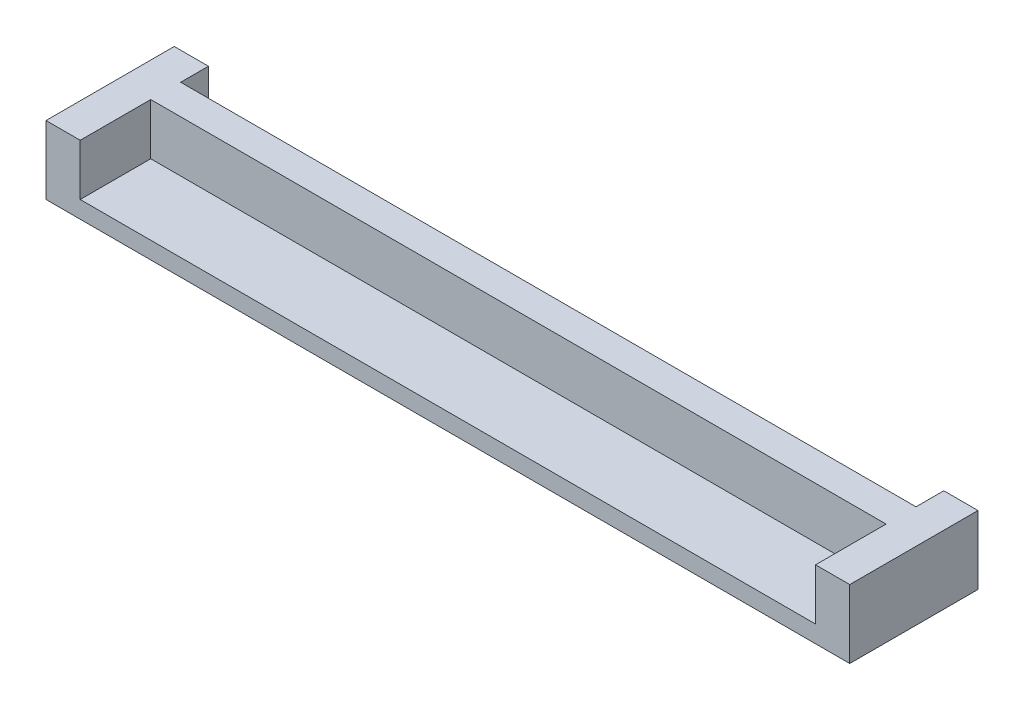
from build123d import *

# Parameters (mm, degrees)
BOSS_EXTRUDE1_DEPTH = 6
SKETCH2_W           = 94
SKETCH2_H           = 15
BOSS_EXTRUDE2_DEPTH = 2


with BuildPart() as part:
    # Sketch1 → Boss-Extrude1 (new body)
    with BuildSketch(Plane(origin=(0, 0, 0), x_dir=(1, 0, 0), z_dir=(0, 1, 0))):
        Polygon((57.138726824, 8.469222481), (61.138726824, 8.469222481), (61.138726824, 5.219222481), (147.138726824, 5.219222481), (147.138726824, 8.469222481), (151.138726824, 8.469222481), (151.138726824, -6.530777519), (147.138726824, -6.530777519), (147.138726824, 1.719222481), (61.138726824, 1.719222481), (61.138726824, -6.530777519), (57.138726824, -6.530777519), align=None)
    extrude(amount=BOSS_EXTRUDE1_DEPTH)

    # Sketch2 → Boss-Extrude2 (add)
    with BuildSketch(Plane.XZ):
        with Locations((104.138726824, -0.969222481)):
            Rectangle(SKETCH2_W, SKETCH2_H)
    extrude(amount=BOSS_EXTRUDE2_DEPTH)


solid = part.part
